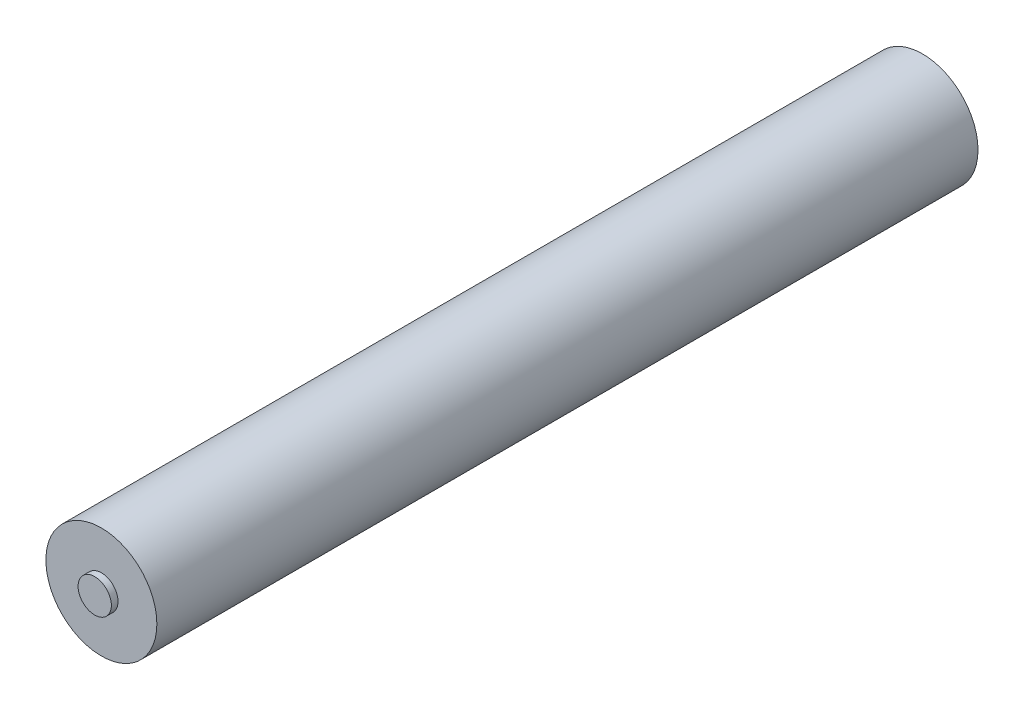
from build123d import *

# Parameters (mm, degrees)
SCHIZZO1_R                   = 25
ESTRUSIONE_ESTRUSIONE1_DEPTH = 370
SCHIZZO2_R                   = 7.5
ESTRUSIONE_ESTRUSIONE2_DEPTH = 3


with BuildPart() as part:
    # Schizzo1 → Estrusione-Estrusione1 (new body)
    with BuildSketch(Plane.XY):
        Circle(SCHIZZO1_R)
    extrude(amount=ESTRUSIONE_ESTRUSIONE1_DEPTH)

    # Schizzo2 → Estrusione-Estrusione2 (add)
    with BuildSketch(Plane.XY.offset(370)):
        Circle(SCHIZZO2_R)
    extrude(amount=ESTRUSIONE_ESTRUSIONE2_DEPTH)


solid = part.part
